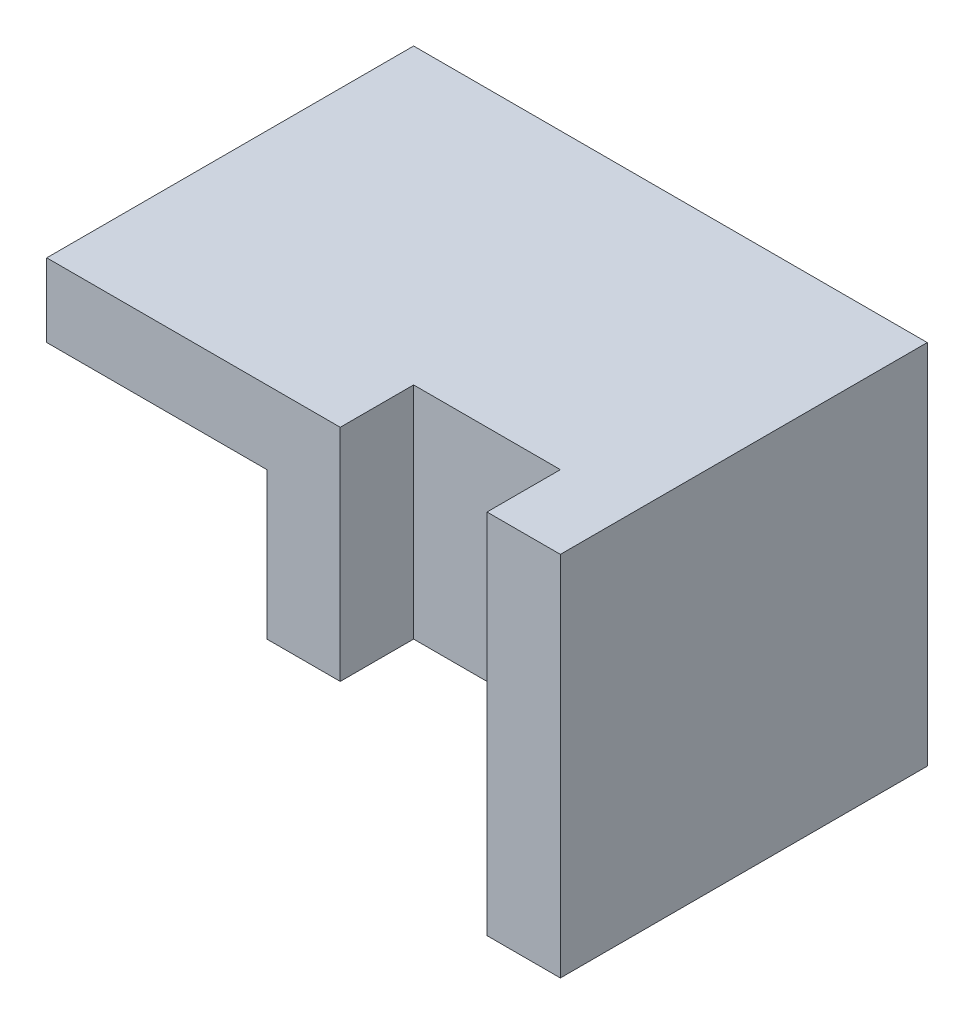
from build123d import *

# Parameters (mm, degrees)
SKETCH1_W           = 70
SKETCH1_H           = 50
BOSS_EXTRUDE1_DEPTH = 50
CUT_EXTRUDE2_DEPTH  = 50
CUT_EXTRUDE4_DEPTH  = 40
SKETCH5_W           = 20
SKETCH5_H           = 10
CUT_EXTRUDE5_DEPTH  = 40


with BuildPart() as part:
    # Sketch1 → Boss-Extrude1 (new body)
    with BuildSketch(Plane.XY):
        with Locations((35, 25)):
            Rectangle(SKETCH1_W, SKETCH1_H)
    extrude(amount=BOSS_EXTRUDE1_DEPTH)

    # Sketch3 → Cut-Extrude2 (cut)
    with BuildSketch(Plane.XY):
        Polygon((0, 30), (20, 0), (0, 0), align=None)
    extrude(amount=CUT_EXTRUDE2_DEPTH, mode=Mode.SUBTRACT)

    # Sketch4 → Cut-Extrude4 (cut)
    with BuildSketch(Plane.XY.offset(50)):
        Polygon((60, 0), (60, 20), (30, 20), (30, 40), (0, 40), (0, 30), (20, 0), align=None)
    extrude(amount=-CUT_EXTRUDE4_DEPTH, mode=Mode.SUBTRACT)

    # Sketch5 → Cut-Extrude5 (cut)
    with BuildSketch(Plane.XZ.offset(-20)):
        with Locations((50, 45)):
            Rectangle(SKETCH5_W, SKETCH5_H)
    extrude(amount=-CUT_EXTRUDE5_DEPTH, mode=Mode.SUBTRACT)


solid = part.part
